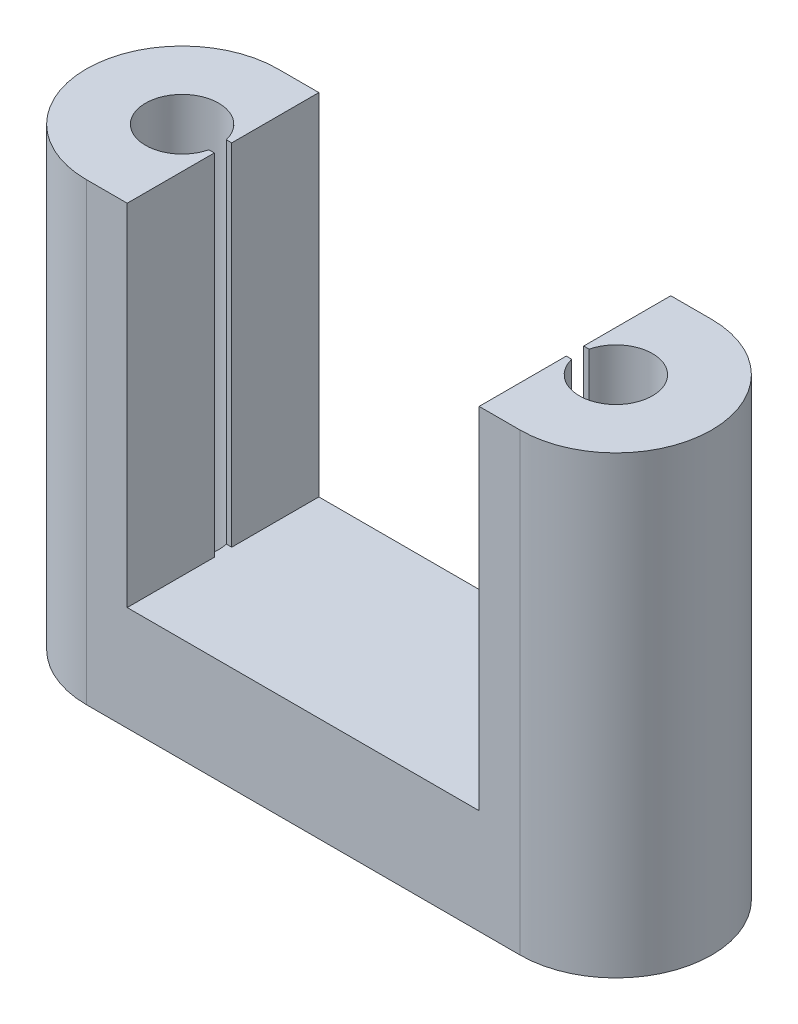
from build123d import *

# Parameters (mm, degrees)
SKETCH1_R           = 2.1
BOSS_EXTRUDE1_DEPTH = 6
BOSS_EXTRUDE2_DEPTH = 20.1


with BuildPart() as part:
    # Sketch1 → Boss-Extrude1 (new body)
    with BuildSketch(Plane(origin=(0, 0, 0), x_dir=(1, 0, 0), z_dir=(0, 1, 0))):
        with BuildLine():
            Line((0, 5.5), (24.9, 5.5))
            ThreePointArc((24.9, 5.5), (30.4, 0), (24.9, -5.5))
            Line((24.9, -5.5), (0, -5.5))
            ThreePointArc((0, -5.5), (-5.5, 0), (0, 5.5))
        make_face()
        Circle(SKETCH1_R, mode=Mode.SUBTRACT)
        with Locations((24.9, 0)):
            Circle(SKETCH1_R, mode=Mode.SUBTRACT)
    extrude(amount=BOSS_EXTRUDE1_DEPTH)

    # Sketch2 → Boss-Extrude2 (add)
    with BuildSketch(Plane(origin=(0, 6, 0), x_dir=(1, 0, 0), z_dir=(0, 1, 0))):
        with BuildLine():
            Line((22.55, 5.5), (22.55, 0.5))
            Line((22.55, 0.5), (22.860392195, 0.5))
            ThreePointArc((22.860392195, 0.5), (27, 0), (22.860392195, -0.5))
            Line((22.860392195, -0.5), (22.55, -0.5))
            Line((22.55, -0.5), (22.55, -5.5))
            Line((22.55, -5.5), (24.9, -5.5))
            ThreePointArc((24.9, -5.5), (30.4, 0), (24.9, 5.5))
            Line((24.9, 5.5), (22.55, 5.5))
        make_face()
        with BuildLine():
            Line((2.35, 5.5), (2.35, 0.5))
            Line((2.35, 0.5), (2.039607805, 0.5))
            ThreePointArc((2.039607805, 0.5), (-2.1, 0), (2.039607805, -0.5))
            Line((2.039607805, -0.5), (2.35, -0.5))
            Line((2.35, -0.5), (2.35, -5.5))
            Line((2.35, -5.5), (0, -5.5))
            ThreePointArc((0, -5.5), (-5.5, 0), (0, 5.5))
            Line((0, 5.5), (2.35, 5.5))
        make_face()
    extrude(amount=BOSS_EXTRUDE2_DEPTH)


solid = part.part
